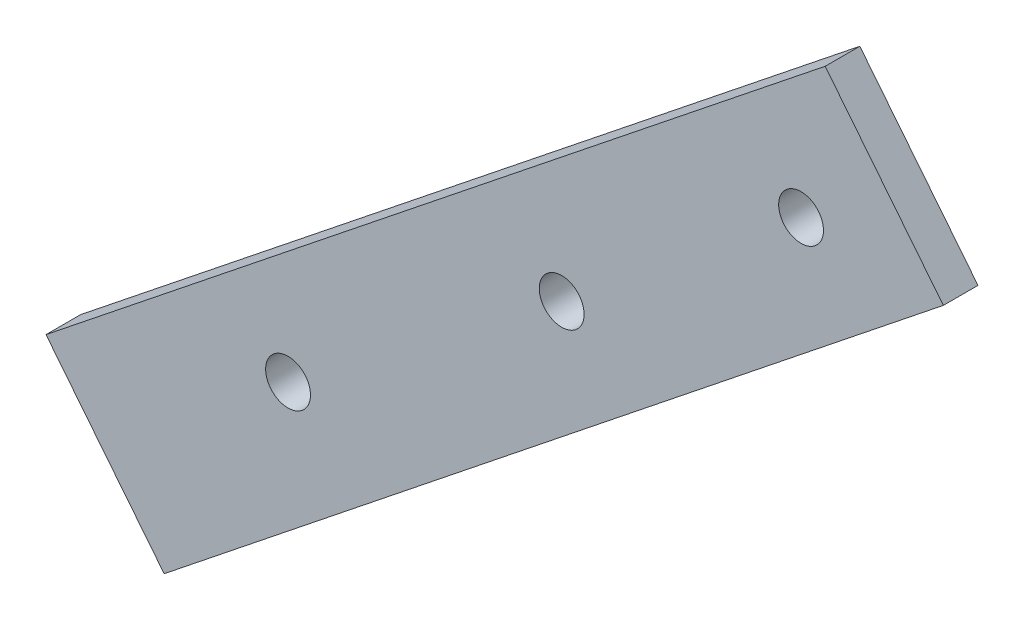
from build123d import *

# Parameters (mm, degrees)
SKETCH1_R           = 6.469950333
BOSS_EXTRUDE1_DEPTH = 10


with BuildPart() as part:
    # Sketch1 → Boss-Extrude1 (new body)
    with BuildSketch(Plane.XY):
        Polygon((0, 0), (-34.094374575, 42.711992732), (190.731046947, 222.176392423), (224.825421522, 179.464399691), align=None)
        with Locations((35.743173778, 65.760421737)):
            Circle(SKETCH1_R, mode=Mode.SUBTRACT)
        with Locations((114.698226452, 125.411384111)):
            Circle(SKETCH1_R, mode=Mode.SUBTRACT)
        with Locations((183.769608582, 180.906879578)):
            Circle(SKETCH1_R, mode=Mode.SUBTRACT)
    extrude(amount=BOSS_EXTRUDE1_DEPTH)


solid = part.part
